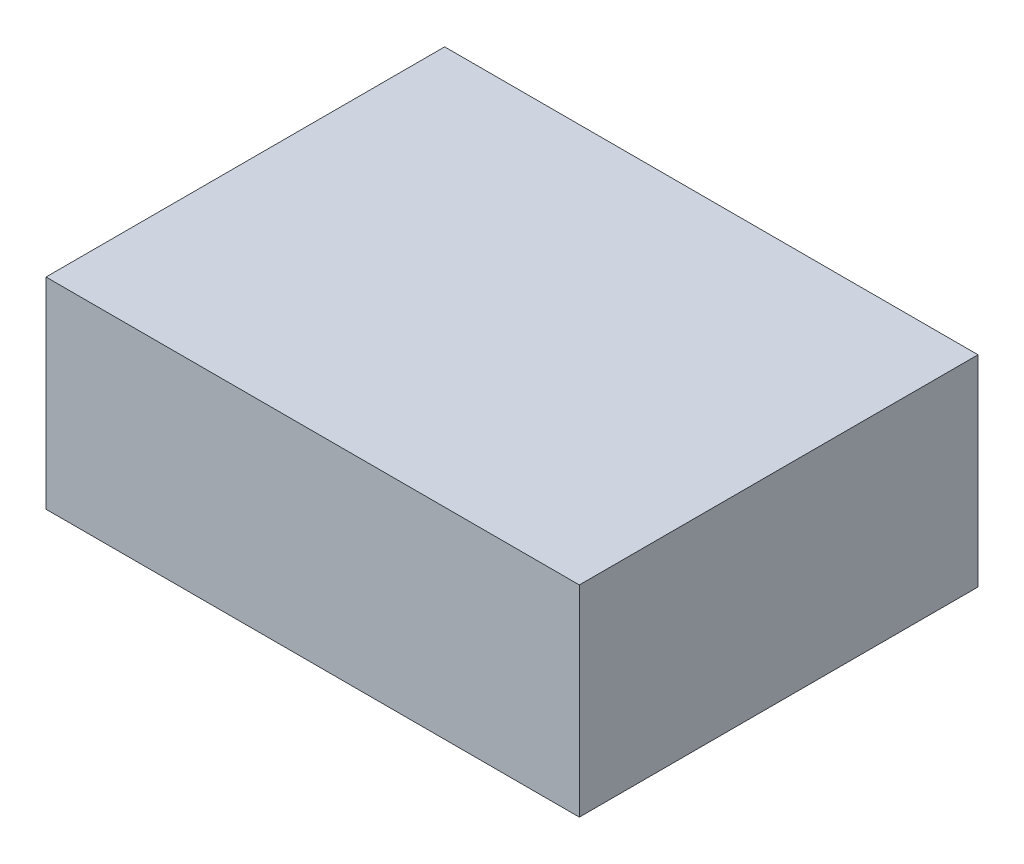
from build123d import *

# Parameters (mm, degrees)
SKETCH1_W           = 7.5438
SKETCH1_H           = 5.6388
BOSS_EXTRUDE1_DEPTH = 2.8448


with BuildPart() as part:
    # Sketch1 → Boss-Extrude1 (new body)
    with BuildSketch(Plane(origin=(0, 0, 0), x_dir=(1, 0, 0), z_dir=(0, 1, 0))):
        with Locations((3.7719, 2.8194)):
            Rectangle(SKETCH1_W, SKETCH1_H)
    extrude(amount=BOSS_EXTRUDE1_DEPTH)


solid = part.part
